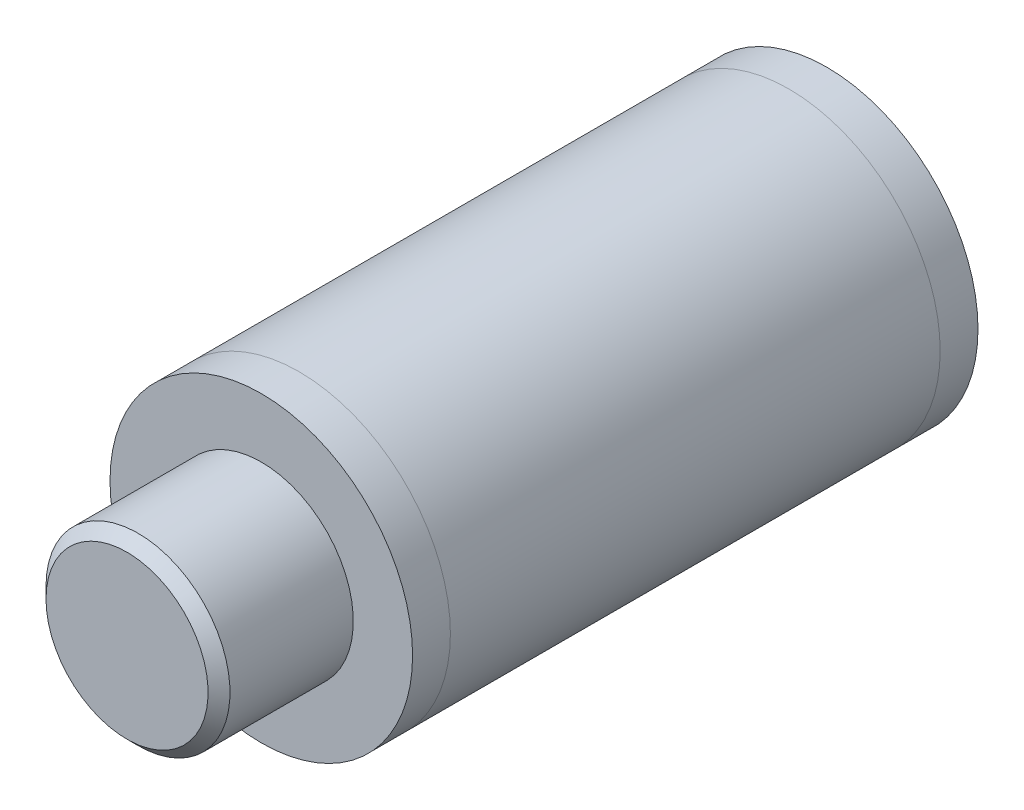
from build123d import *

# Parameters (mm, degrees)
SKETCH1_W = 8
SKETCH1_H = 29.9


with BuildPart() as part:
    # Sketch1 → Revolve1 (revolve)
    with BuildSketch(Plane(origin=(0, 0, 0), x_dir=(-1, 0, 0), z_dir=(0, 1, 0)), mode=Mode.PRIVATE) as revolve1_sk:
        with Locations((-4, 14.95)):
            Rectangle(SKETCH1_W, SKETCH1_H)
    revolve(revolve1_sk.sketch.rotate(Axis((0, 0, 29.9), (0, 0, -1)), 180), axis=Axis((0, 0, 29.9), (0, 0, -1)))  # turned: the seam where the file's is

    # Sketch2 → Revolve2 (revolve)
    with BuildSketch(Plane(origin=(0, 0, 0), x_dir=(-1, 0, 0), z_dir=(0, 1, 0)), mode=Mode.PRIVATE) as revolve2_sk:
        Polygon((0, 29.9), (-4.865, 29.9), (-4.865, 36.42), (-4.285, 37), (0, 37), align=None)
    revolve(revolve2_sk.sketch.rotate(Axis((0, 0, 37), (0, 0, -1)), 180), axis=Axis((0, 0, 37), (0, 0, -1)))  # turned: the seam where the file's is


solid = part.part
